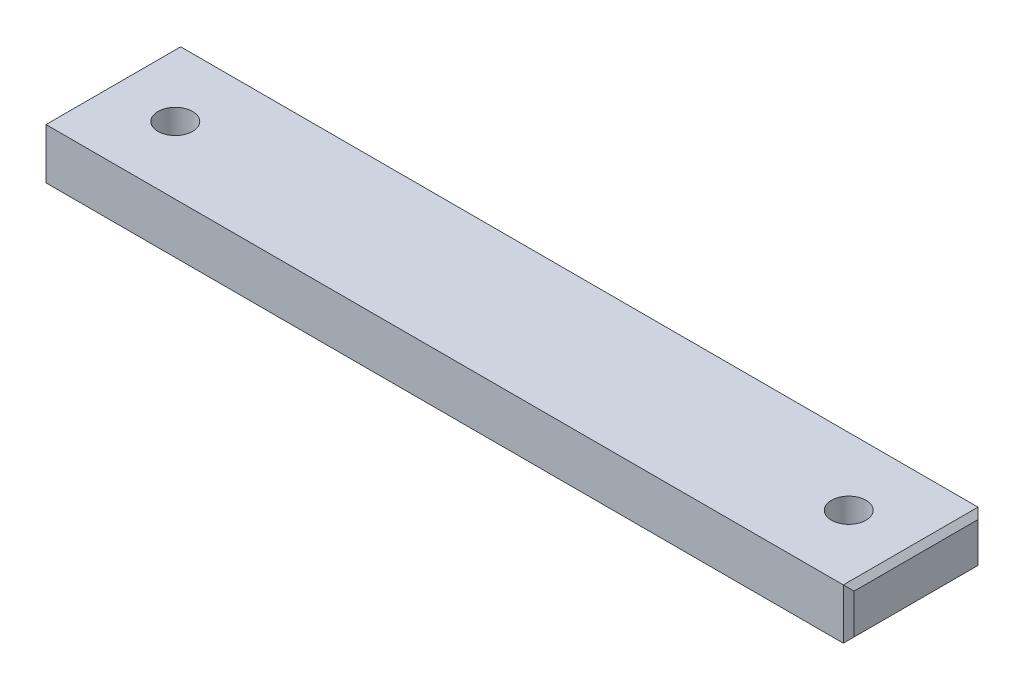
from build123d import *

# Parameters (mm, degrees)
SKETCH1_W                                         = 76.2
SKETCH1_H                                         = 12.7
BOSS_EXTRUDE2_DEPTH                               = 4.7625
F_4_CLEARANCE_HOLE1_D                             = 3.2639
CSK_FOR_4_FLAT_HEAD_SOCKET_CAP_SCREW2_D           = 3.2639
CSK_FOR_4_FLAT_HEAD_SOCKET_CAP_SCREW2_CSINK_D     = 6.477
CSK_FOR_4_FLAT_HEAD_SOCKET_CAP_SCREW2_CSINK_ANGLE = 82
CHAMFER1_SIZE                                     = 0.508


with BuildPart() as part:
    # Sketch1 → Boss-Extrude2 (new body)
    with BuildSketch(Plane(origin=(0, 0, 0), x_dir=(1, 0, 0), z_dir=(0, 1, 0))):
        with Locations((-31.75, 0)):
            Rectangle(SKETCH1_W, SKETCH1_H)
    extrude(amount=BOSS_EXTRUDE2_DEPTH)

    # #4 Clearance Hole1 (through all)
    with Locations(Plane(origin=(0, 4.7625, 0), x_dir=(1, 0, 0), z_dir=(0, 1, 0))):
        with Locations((-63.5, 0)):
            Hole(F_4_CLEARANCE_HOLE1_D / 2)

    # CSK for #4 Flat Head Socket Cap Screw2 (through all)
    with Locations(Plane(origin=(0, 0, 0), x_dir=(-1, 0, 0), z_dir=(0, -1, 0))):
        with Locations((0, 0)):
            CounterSinkHole(CSK_FOR_4_FLAT_HEAD_SOCKET_CAP_SCREW2_D / 2, CSK_FOR_4_FLAT_HEAD_SOCKET_CAP_SCREW2_CSINK_D / 2, counter_sink_angle=CSK_FOR_4_FLAT_HEAD_SOCKET_CAP_SCREW2_CSINK_ANGLE)

    # Chamfer1
    chamfer1_edges = [part.edges().sort_by_distance(p)[0] for p in [
        (-69.85, 2.38125, 6.35),
        (-69.85, 2.38125, -6.35),
        (6.35, 2.38125, -6.35),
        (6.35, 2.38125, 6.35),
        (6.35, 4.7625, 0),
        (-69.85, 4.7625, 0),
        (-69.85, 0, 0),
        (6.35, 0, 0),
    ]]
    chamfer(chamfer1_edges, length=CHAMFER1_SIZE)


solid = part.part
